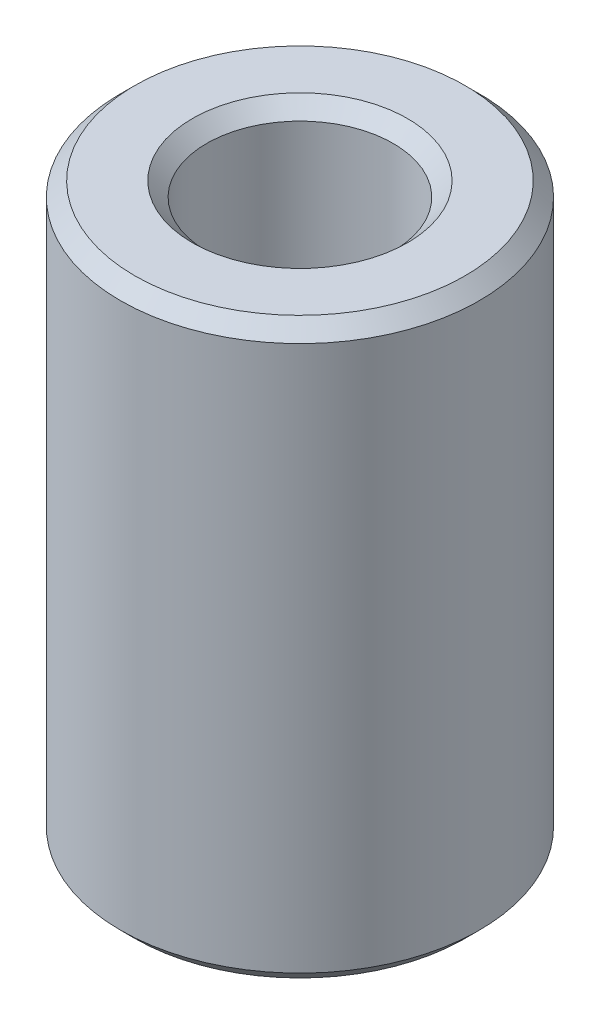
from build123d import *

# Parameters (mm, degrees)
SKIZZE1_R                       = 2.5
SKIZZE1_R_2                     = 1.3
AUFSATZ_LINEAR_AUSTRAGEN1_DEPTH = 8
FASE1_SIZE                      = 0.2


with BuildPart() as part:
    # Skizze1 → Aufsatz-Linear austragen1 (new body)
    with BuildSketch(Plane(origin=(0, 0, 0), x_dir=(1, 0, 0), z_dir=(0, 1, 0))):
        Circle(SKIZZE1_R)
        Circle(SKIZZE1_R_2, mode=Mode.SUBTRACT)
    extrude(amount=AUFSATZ_LINEAR_AUSTRAGEN1_DEPTH)

    # Fase1
    fase1_edges = [part.edges().sort_by_distance(p)[0] for p in [
        (-2.5, 0, 0),
        (-2.5, 8, 0),
        (-1.3, 0, 0),
        (-1.3, 8, 0),
    ]]
    chamfer(fase1_edges, length=FASE1_SIZE)


solid = part.part
